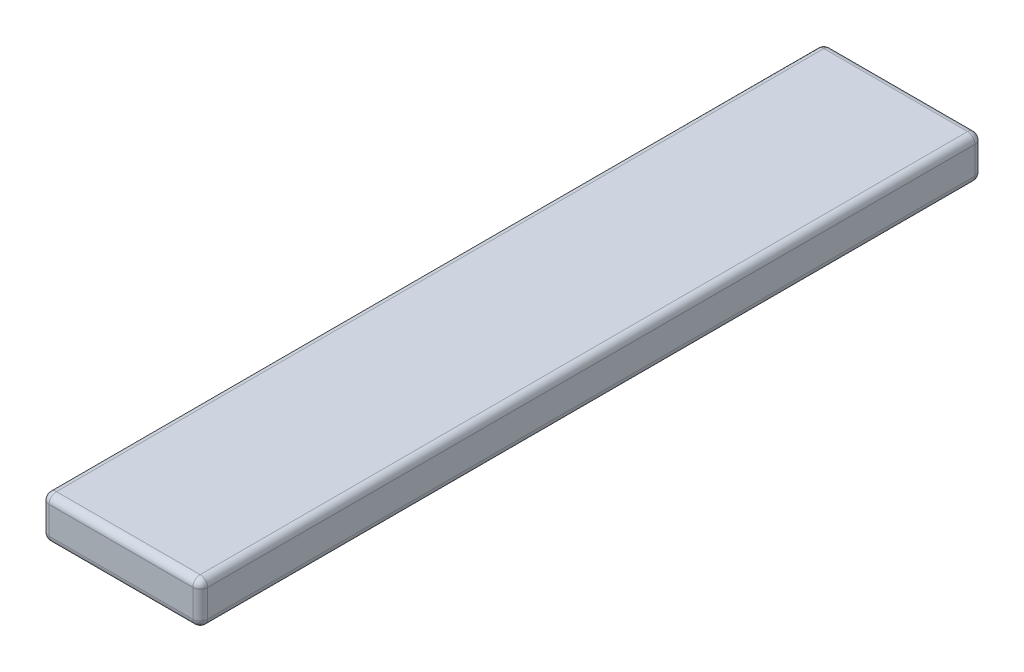
from build123d import *

# Parameters (mm, degrees)
SKETCH1_W           = 750
SKETCH1_H           = 3700
BOSS_EXTRUDE1_DEPTH = 200
FILLET1_R           = 35


with BuildPart() as part:
    # Sketch1 → Boss-Extrude1 (new body)
    with BuildSketch(Plane(origin=(0, 0, 0), x_dir=(1, 0, 0), z_dir=(0, 1, 0))):
        with Locations((0, -885.305343511)):
            Rectangle(SKETCH1_W, SKETCH1_H)
    extrude(amount=BOSS_EXTRUDE1_DEPTH)

    # Fillet1
    fillet1_edges = [part.edges().sort_by_distance(p)[0] for p in [
        (-375, 200, 885.305343511),
        (0, 200, 2735.305343511),
        (375, 200, 885.305343511),
        (0, 0, 2735.305343511),
        (-375, 0, 885.305343511),
        (0, 0, -964.694656489),
        (375, 0, 885.305343511),
        (375, 100, 2735.305343511),
        (-375, 100, 2735.305343511),
        (-375, 100, -964.694656489),
        (375, 100, -964.694656489),
        (0, 200, -964.694656489),
    ]]
    fillet(fillet1_edges, radius=FILLET1_R)


solid = part.part
